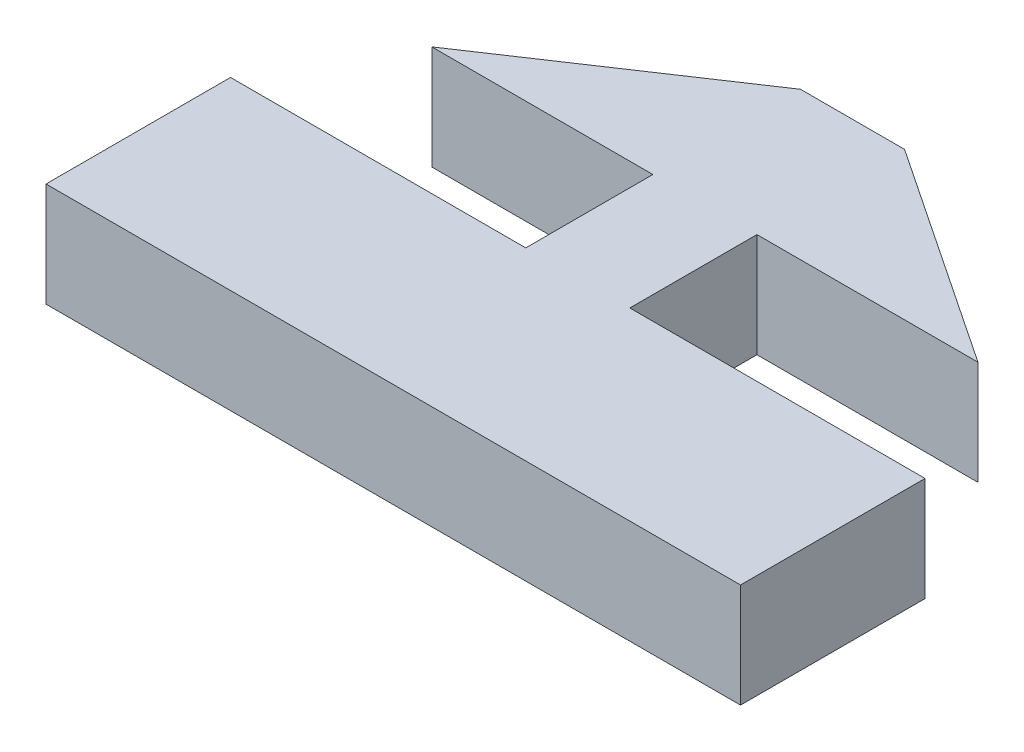
from build123d import *

# Parameters (mm, degrees)
BOSS_EXTRUDE1_DEPTH = 3.5814


with BuildPart() as part:
    # Sketch1 → Boss-Extrude1 (new body)
    with BuildSketch(Plane(origin=(0, 0, 0), x_dir=(1, 0, 0), z_dir=(0, 1, 0))):
        Polygon((-11.9507, -8.5374988), (11.9507, -8.5374988), (11.9507, -2.1874988), (1.7907, -2.1874988), (1.7907, 2.1874988), (9.398, 2.1874988), (1.7907, 7.2674988), (-1.7907, 7.2674988), (-9.398, 2.1874988), (-1.7907, 2.1874988), (-1.7907, -2.1874988), (-11.9507, -2.1874988), align=None)
    extrude(amount=BOSS_EXTRUDE1_DEPTH)


solid = part.part
